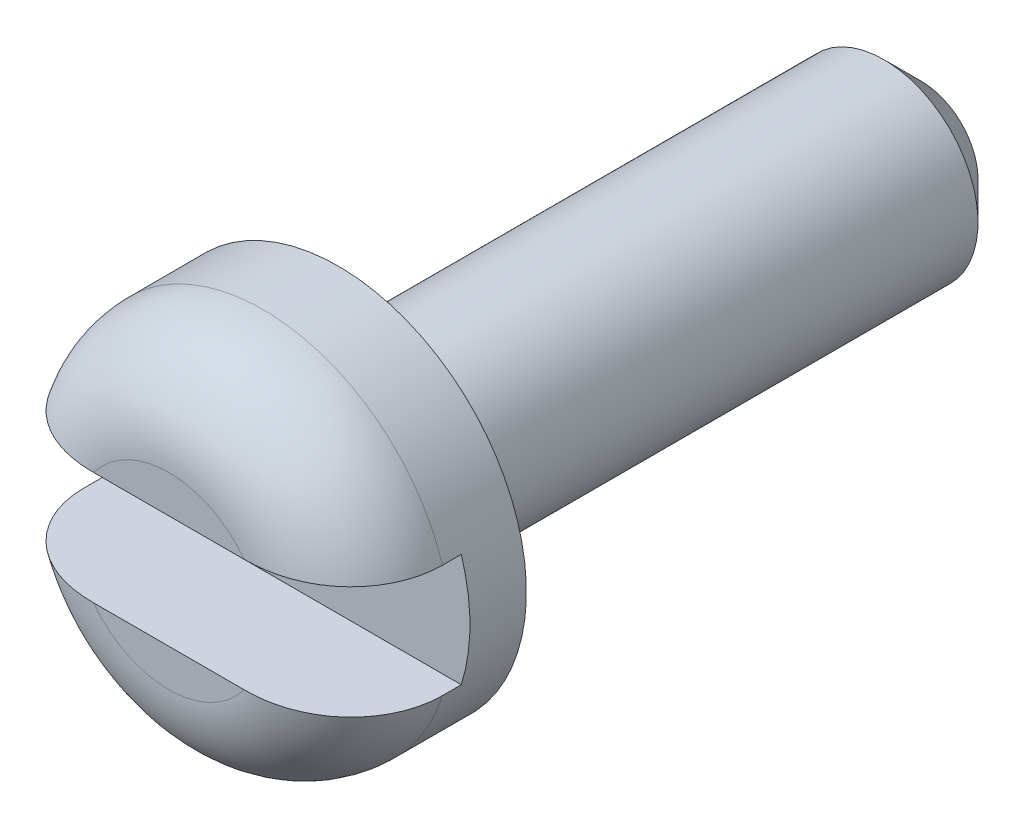
from build123d import *

# Parameters (mm, degrees)
SKETCH_2_W               = 1.2
SKETCH_2_H               = 1.2
CUT_EXTRUDE_1_DEPTH      = 3
CUT_EXTRUDE_1_DEPTH_BACK = 3
CHAMFER_1_SIZE           = 0.4
FILLET_1_R               = 1
FILLET_2_R               = 0.4


with BuildPart() as part:
    # Эскиз1 → Повернуть1 (revolve)
    with BuildSketch(Plane(origin=(0, 0, 0), x_dir=(1, 0, 0), z_dir=(0, 1, 0))):
        Polygon((0, 0), (-2, 0), (-2, 1.8), (-1, 1.8), (-1, 8), (0, 8), align=None)
    revolve(axis=Axis((0, 0, -8), (0, 0, 1)))

    # Эскиз2 → Вырез-Вытянуть1 (cut, two sides)
    with BuildSketch(Plane(origin=(0, 0, 0), x_dir=(0, 0, -1), z_dir=(1, 0, 0))) as cut_extrude_1_sk:
        with Locations((0.6, 0)):
            Rectangle(SKETCH_2_W, SKETCH_2_H)
    extrude(amount=CUT_EXTRUDE_1_DEPTH, mode=Mode.SUBTRACT)
    extrude(cut_extrude_1_sk.sketch, amount=-CUT_EXTRUDE_1_DEPTH_BACK, mode=Mode.SUBTRACT)

    # Фаска1
    chamfer_1_edges = [part.edges().sort_by_distance(p)[0] for p in [
        (1, 0, -8),
    ]]
    chamfer(chamfer_1_edges, length=CHAMFER_1_SIZE)

    # Скругление1
    fillet_1_edges = [part.edges().sort_by_distance(p)[0] for p in [
        (0, 2, 0),
        (0, -2, 0),
    ]]
    fillet(fillet_1_edges, radius=FILLET_1_R)

    # Скругление2
    fillet_2_edges = [part.edges().sort_by_distance(p)[0] for p in [
        (1, 0, -1.8),
    ]]
    fillet(fillet_2_edges, radius=FILLET_2_R)


solid = part.part
